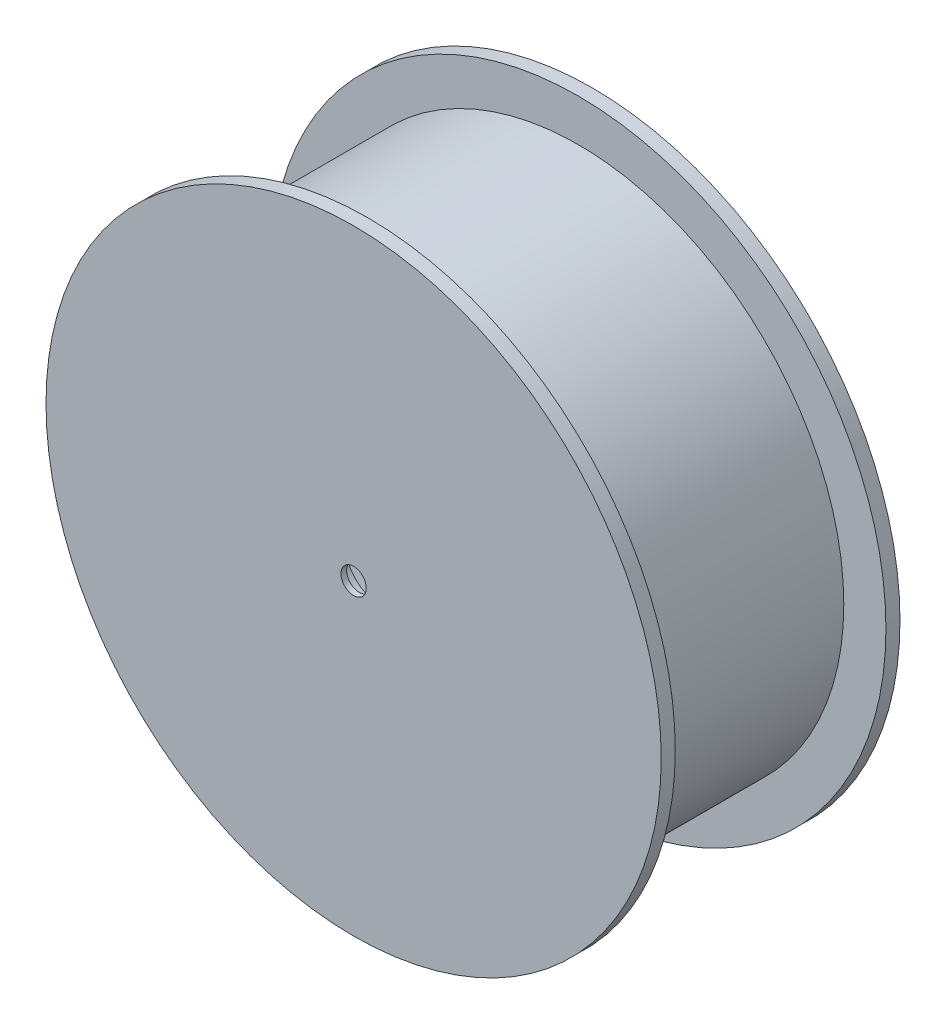
from build123d import *

# Parameters (mm, degrees)
SKETCH5_R          = 4.5
CUT_EXTRUDE1_DEPTH = 86
SKETCH6_R          = 13
CUT_EXTRUDE2_DEPTH = 8
CUT_EXTRUDE4_DEPTH = 3
SKETCH9_R          = 1
CUT_EXTRUDE5_DEPTH = 5


with BuildPart() as part:
    # Sketch3 → Revolve1 (revolve)
    with BuildSketch(Plane(origin=(0, 0, 0), x_dir=(0, 0, -1), z_dir=(1, 0, 0))):
        Polygon((-24.411764706, 0), (-24.411764706, -109.5), (-19.411764706, -109.5), (-19.411764706, -94.5), (55.588235294, -94.5), (55.588235294, -109.5), (60.588235294, -109.5), (60.588235294, -84.5), (-14.411764706, -84.5), (-14.411764706, 0), align=None)
    revolve(axis=Axis((0, 0, 33.897058824), (0, 0, -1)))

    # Sketch5 → Cut-Extrude1 (cut, through all)
    with BuildSketch(Plane.XY.offset(24.411764706)):
        Circle(SKETCH5_R)
    extrude(amount=-CUT_EXTRUDE1_DEPTH, mode=Mode.SUBTRACT)

    # Sketch6 → Cut-Extrude2 (cut)
    with BuildSketch(Plane(origin=(0, 0, 14.411764706), x_dir=(-1, 0, 0), z_dir=(0, 0, -1))):
        Circle(SKETCH6_R)
    extrude(amount=-CUT_EXTRUDE2_DEPTH, mode=Mode.SUBTRACT)

    # Sketch8 → Cut-Extrude4 (cut)
    with BuildSketch(Plane(origin=(0, 0, -60.588235294), x_dir=(-1, 0, 0), z_dir=(0, 0, -1))):
        with BuildLine():
            ThreePointArc((11.969710732, 83.647928994), (0, 96.5), (-11.969710732, 83.647928994))
            ThreePointArc((-11.969710732, 83.647928994), (0, 84.5), (11.969710732, 83.647928994))
        make_face()
        with BuildLine():
            ThreePointArc((78.426086849, 31.457890927), (83.571451465, 48.25), (66.456376117, 52.190038067))
            ThreePointArc((66.456376117, 52.190038067), (73.17914662, 42.25), (78.426086849, 31.457890927))
        make_face()
        with BuildLine():
            ThreePointArc((66.456376117, -52.190038067), (83.571451465, -48.25), (78.426086849, -31.457890927))
            ThreePointArc((78.426086849, -31.457890927), (73.17914662, -42.25), (66.456376117, -52.190038067))
        make_face()
        with BuildLine():
            ThreePointArc((-11.969710732, -83.647928994), (0, -96.5), (11.969710732, -83.647928994))
            ThreePointArc((11.969710732, -83.647928994), (0, -84.5), (-11.969710732, -83.647928994))
        make_face()
        with BuildLine():
            ThreePointArc((-78.426086849, -31.457890927), (-83.571451465, -48.25), (-66.456376117, -52.190038067))
            ThreePointArc((-66.456376117, -52.190038067), (-73.17914662, -42.25), (-78.426086849, -31.457890927))
        make_face()
        with BuildLine():
            ThreePointArc((-66.456376117, 52.190038067), (-83.571451465, 48.25), (-78.426086849, 31.457890927))
            ThreePointArc((-78.426086849, 31.457890927), (-73.17914662, 42.25), (-66.456376117, 52.190038067))
        make_face()
    extrude(amount=-CUT_EXTRUDE4_DEPTH, mode=Mode.SUBTRACT)

    # Sketch9 → Cut-Extrude5 (cut)
    with BuildSketch(Plane(origin=(0, 0, -57.588235294), x_dir=(-1, 0, 0), z_dir=(0, 0, -1))):
        with Locations((0, 90.5)):
            Circle(SKETCH9_R)
        with Locations((78.375299042, 45.25)):
            Circle(SKETCH9_R)
        with Locations((78.375299042, -45.25)):
            Circle(SKETCH9_R)
        with Locations((0, -90.5)):
            Circle(SKETCH9_R)
        with Locations((-78.375299042, -45.25)):
            Circle(SKETCH9_R)
        with Locations((-78.375299042, 45.25)):
            Circle(SKETCH9_R)
    extrude(amount=-CUT_EXTRUDE5_DEPTH, mode=Mode.SUBTRACT)


solid = part.part
